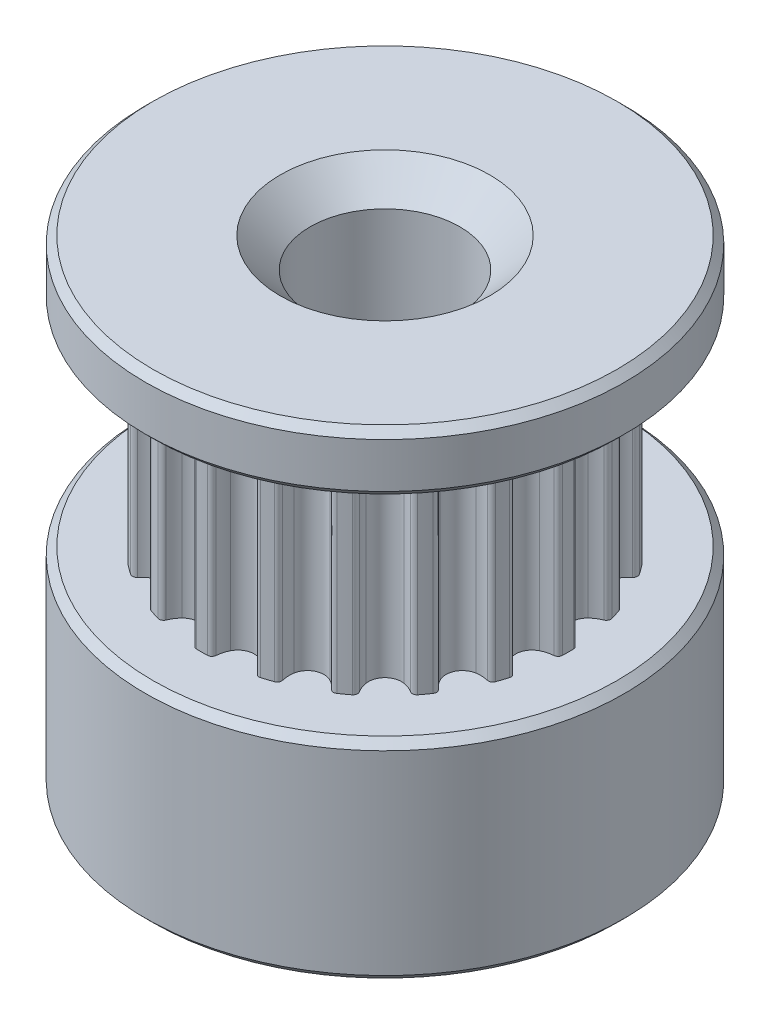
from build123d import *

# Parameters (mm, degrees)
SKETCH2_R           = 6.366197724
BOSS_EXTRUDE1_DEPTH = 7
CUT_EXTRUDE1_DEPTH  = 7
CIRPATTERN1_COUNT   = 20
SKETCH4_R           = 8
BOSS_EXTRUDE2_DEPTH = 7
BOSS_EXTRUDE3_START = -7
SKETCH4_2_R         = 8
BOSS_EXTRUDE3_DEPTH = 2
SKETCH5_R           = 2.5
CUT_EXTRUDE2_DEPTH  = 17
CHAMFER1_SIZE       = 0.25
CHAMFER2_SIZE       = 1


with BuildPart() as part:
    # Sketch2 → Boss-Extrude1 (new body)
    with BuildSketch(Plane(origin=(0, 0, 0), x_dir=(1, 0, 0), z_dir=(0, 1, 0))):
        Circle(SKETCH2_R)
    extrude(amount=BOSS_EXTRUDE1_DEPTH)

    # Sketch3 → Cut-Extrude1 (cut)
    with BuildSketch(Plane(origin=(0, 7, 0), x_dir=(1, 0, 0), z_dir=(0, 1, 0))):
        with BuildLine():
            Line((0, 6.112197724), (0, 6.742197724))
            ThreePointArc((0, 6.742197724), (1.054712094, 6.659190082), (2.083453676, 6.412211079))
            Line((2.083453676, 6.412211079), (1.88877297, 5.813045474))
            ThreePointArc((1.88877297, 5.813045474), (1.800590387, 5.840961845), (1.711995454, 5.86754059))
            ThreePointArc((1.711995454, 5.86754059), (1.604497475, 5.85849614), (1.530869486, 5.779651122))
            ThreePointArc((1.530869486, 5.779651122), (1.440193428, 5.606086389), (1.317431187, 5.453520678))
            ThreePointArc((1.317431187, 5.453520678), (0.838706942, 5.295387226), (0.432279053, 5.593715003))
            ThreePointArc((0.432279053, 5.593715003), (0.362670622, 5.776749236), (0.330067019, 5.969839549))
            ThreePointArc((0.330067019, 5.969839549), (0.284407089, 6.067577917), (0.184965325, 6.109398403))
            ThreePointArc((0.184965325, 6.109398403), (0.092493253, 6.111497853), (0, 6.112197724))
        make_face()
    cut_extrude1 = extrude(amount=-CUT_EXTRUDE1_DEPTH, mode=Mode.SUBTRACT)

    # CirPattern1: Cut-Extrude1 ×20 about axis
    cirpattern1_axis = Axis((0, 0, 0), (0, 1, 0))
    for i in range(1, CIRPATTERN1_COUNT):
        add(cut_extrude1.rotate(cirpattern1_axis, i * 360 / CIRPATTERN1_COUNT), mode=Mode.SUBTRACT)

    # Sketch4 → Boss-Extrude2 (add)
    with BuildSketch(Plane.XZ):
        Circle(SKETCH4_R)
    extrude(amount=BOSS_EXTRUDE2_DEPTH)

    # Sketch4_2 → Boss-Extrude3 (add)
    with BuildSketch(Plane.XZ.offset(BOSS_EXTRUDE3_START)):
        Circle(SKETCH4_2_R)
    extrude(amount=-BOSS_EXTRUDE3_DEPTH)

    # Sketch5 → Cut-Extrude2 (cut, through all)
    with BuildSketch(Plane.XZ.offset(7)):
        Circle(SKETCH5_R)
    extrude(amount=-CUT_EXTRUDE2_DEPTH, mode=Mode.SUBTRACT)

    # Chamfer1
    chamfer1_edges = [part.edges().sort_by_distance(p)[0] for p in [
        (-8, 0, 0),
        (-8, -7, 0),
        (-8, 7, 0),
        (-8, 9, 0),
    ]]
    chamfer(chamfer1_edges, length=CHAMFER1_SIZE)

    # Chamfer2
    chamfer2_edges = [part.edges().sort_by_distance(p)[0] for p in [
        (-2.5, 9, 0),
    ]]
    chamfer(chamfer2_edges, length=CHAMFER2_SIZE)


solid = part.part
